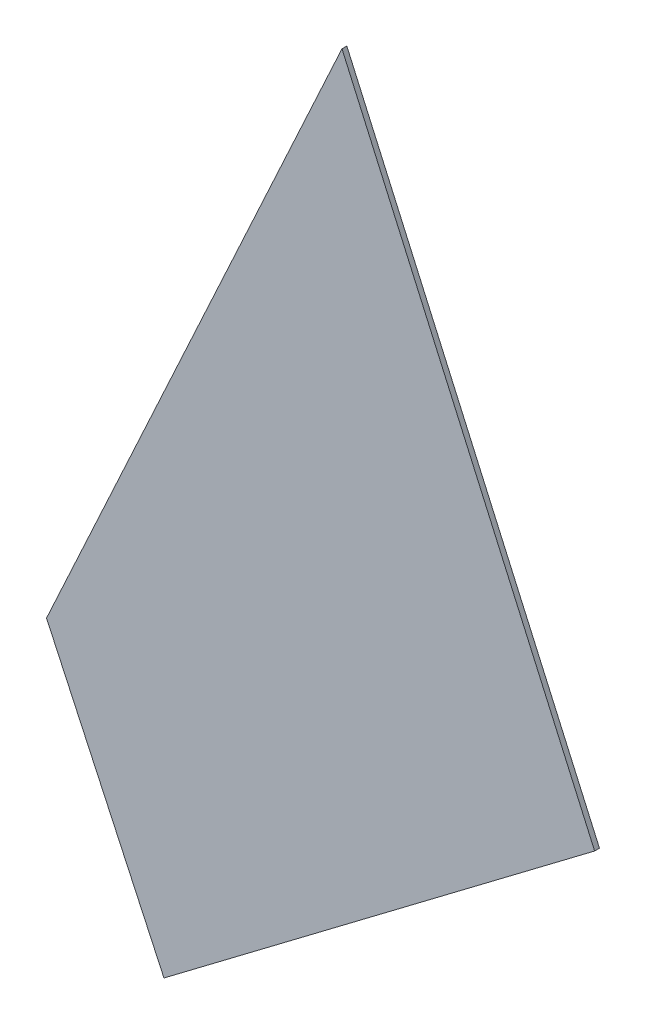
from build123d import *

# Parameters (mm, degrees)
SALIENTE_EXTRUIR1_DEPTH = 0.1


with BuildPart() as part:
    # Model → Saliente-Extruir1 (new body)
    with BuildSketch(Plane.XY):
        Polygon((51.161258051, 15.555534113), (45.938881991, 27.30453113), (39.831918887, 14.06059302), (42.259504026, 8.831907672), align=None)
    extrude(amount=SALIENTE_EXTRUIR1_DEPTH)


solid = part.part
